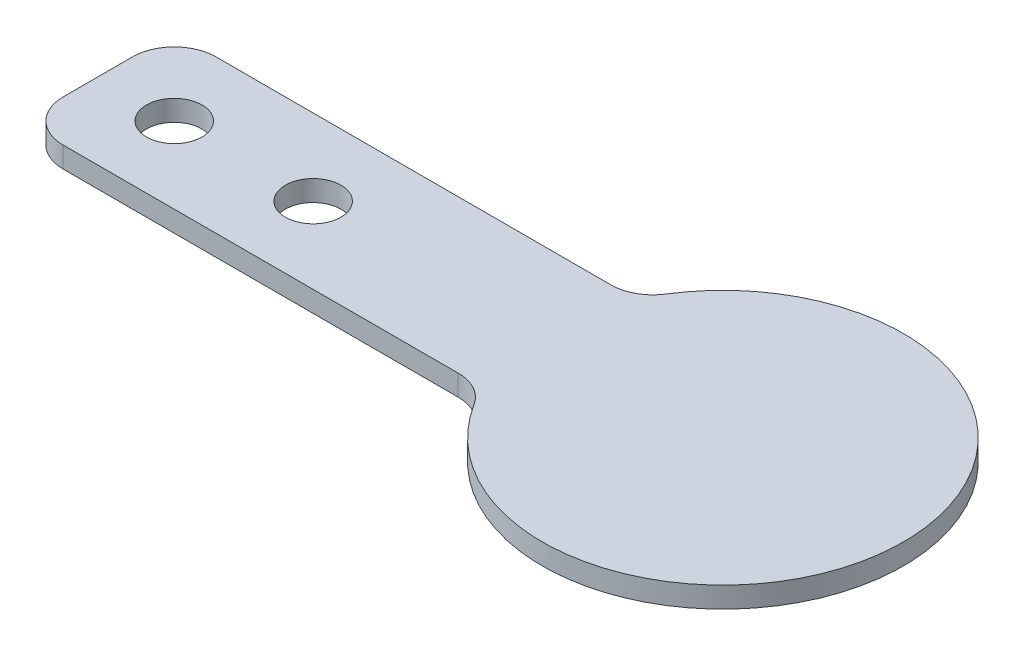
from build123d import *

# Parameters (mm, degrees)
SKETCH_1_R      = 2
EXTRUDE_1_DEPTH = 1.5


with BuildPart() as part:
    # Эскиз1 → Бобышка-Вытянуть1 (new body)
    with BuildSketch(Plane(origin=(0, 0, 0), x_dir=(1, 0, 0), z_dir=(0, 1, 0))):
        with BuildLine():
            Line((3, 0), (31.444558288, 0))
            ThreePointArc((31.444558288, 0), (32.896927043, 0.375), (33.986203609, 1.40625))
            ThreePointArc((33.986203609, 1.40625), (58, -5.5), (33.986203609, -12.40625))
            ThreePointArc((33.986203609, -12.40625), (32.896927043, -11.375), (31.444558288, -11))
            Line((31.444558288, -11), (3, -11))
            ThreePointArc((3, -11), (0.878679656, -10.121320344), (0, -8))
            Line((0, -8), (0, -3))
            ThreePointArc((0, -3), (0.878679656, -0.878679656), (3, 0))
        make_face()
        with Locations((5.5, -5.5)):
            Circle(SKETCH_1_R, mode=Mode.SUBTRACT)
        with Locations((15.5, -5.5)):
            Circle(SKETCH_1_R, mode=Mode.SUBTRACT)
    extrude(amount=EXTRUDE_1_DEPTH)


solid = part.part
